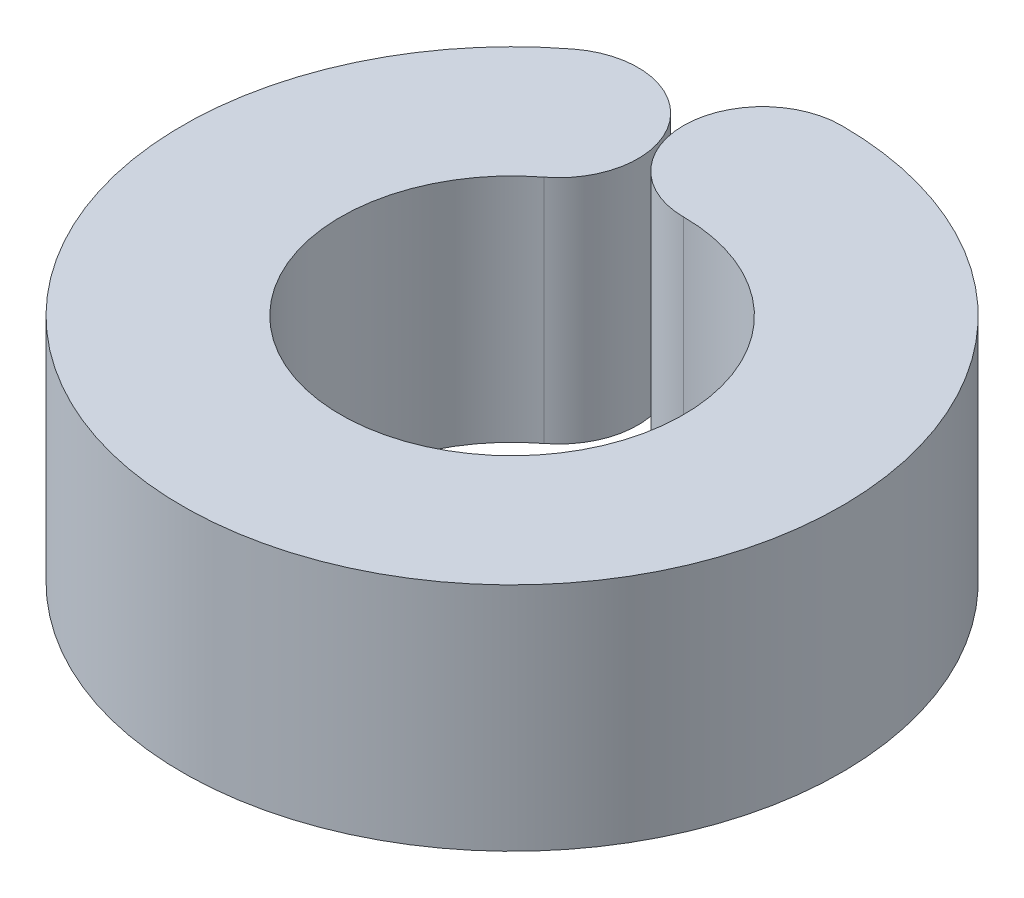
from build123d import *

# Parameters (mm, degrees)
BOSS_EXTRUDE1_DEPTH = 3.5


with BuildPart() as part:
    # Sketch1 → Boss-Extrude1 (new body)
    with BuildSketch(Plane(origin=(0, 0, 0), x_dir=(1, 0, 0), z_dir=(0, 1, 0))):
        with BuildLine():
            ThreePointArc((0, 2.6), (0.833935879, -2.4626309), (-1.579750972, 2.065039192))
            ThreePointArc((-1.579750972, 2.065039192), (-1.355771794, 3.747250038), (-3.037982639, 3.971229216))
            ThreePointArc((-3.037982639, 3.971229216), (1.603722844, -4.735828654), (0, 5))
            ThreePointArc((0, 5), (-1.2, 3.8), (0, 2.6))
        make_face()
    extrude(amount=BOSS_EXTRUDE1_DEPTH)


solid = part.part
